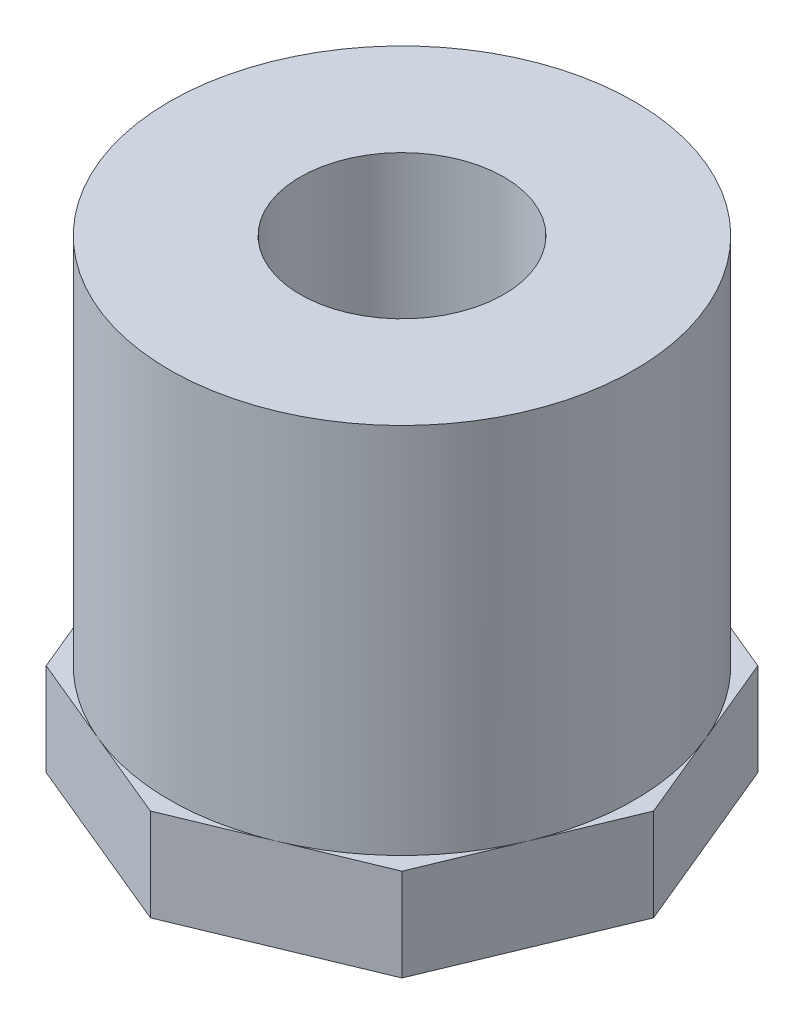
from build123d import *

# Parameters (mm, degrees)
SKETCH1_W           = 12.7
SKETCH1_H           = 25.4
BOSS_EXTRUDE1_DEPTH = 5.0546


with BuildPart() as part:
    # Sketch1 → Revolve1 (revolve)
    with BuildSketch(Plane.XY):
        with Locations((-6.35, 12.7)):
            Rectangle(SKETCH1_W, SKETCH1_H)
    revolve(axis=Axis((0, 0, 0), (0, -1, 0)))

    # Sketch2 → Boss-Extrude1 (add)
    with BuildSketch(Plane.XZ):
        Polygon((0, 13.746380944), (-9.720159182, 9.720159182), (-13.746380944, 0), (-9.720159182, -9.720159182), (0, -13.746380944), (9.720159182, -9.720159182), (13.746380944, 0), (9.720159182, 9.720159182), align=None)
    extrude(amount=-BOSS_EXTRUDE1_DEPTH)

    # Sketch4 → 1/4 NPT Tapped Hole1 (revolve, cut)
    with BuildSketch(Plane(origin=(0, 0, 0), x_dir=(0, 0, -1), z_dir=(1, 0, 0))):
        Polygon((0, 0), (0, 25.4), (5.5626, 25.4), (5.5626, 10.0203), (5.943679799, 10.0203), (6.243701, 0), align=None)
    revolve(axis=Axis((0, -6.35, 0), (0, 1, 0)), mode=Mode.SUBTRACT)


solid = part.part
